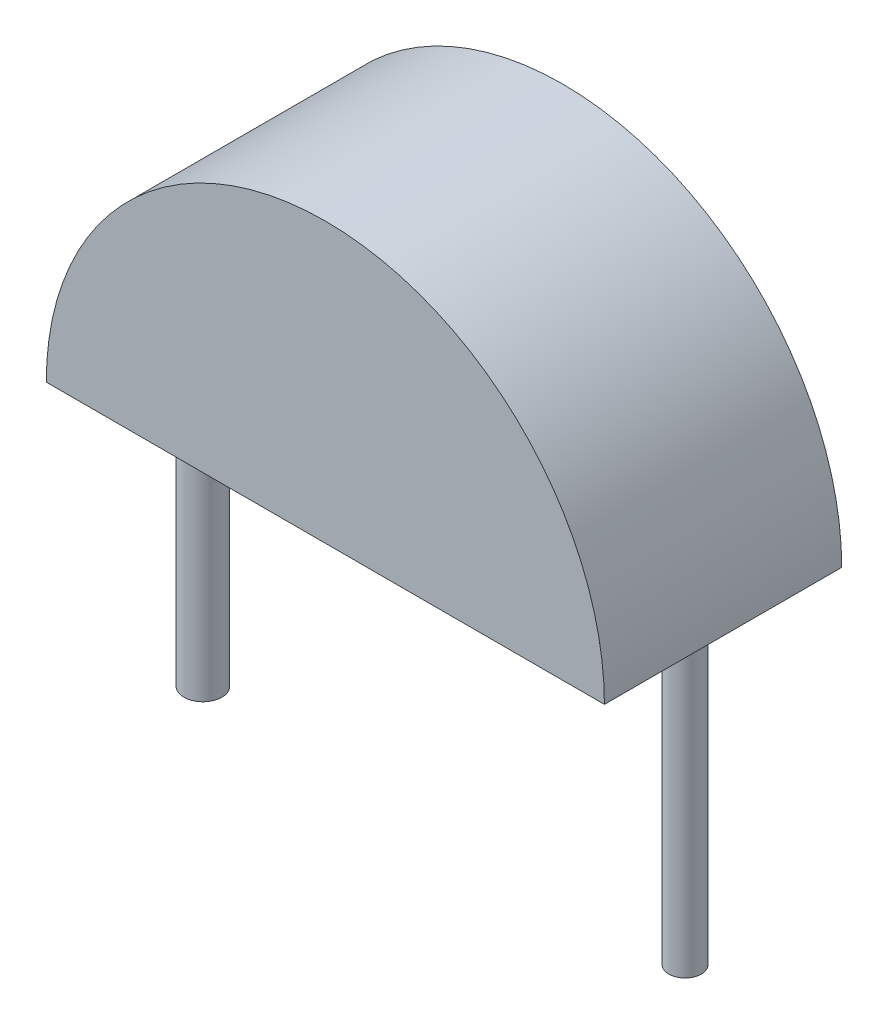
from build123d import *

# Parameters (mm, degrees)
BOSS_EXTRUDE1_DEPTH = 2.5
SKETCH2_R           = 0.2
SKETCH2_R_2         = 0.171619636
BOSS_EXTRUDE2_DEPTH = 3.2


with BuildPart() as part:
    # Sketch1 → Boss-Extrude1 (new body)
    with BuildSketch(Plane.XY):
        with BuildLine():
            Line((-2.94, 0), (2.94, 0))
            ThreePointArc((2.94, 0), (0, 2.94), (-2.94, 0))
        make_face()
    extrude(amount=BOSS_EXTRUDE1_DEPTH)

    # Sketch2 → Boss-Extrude2 (add)
    with BuildSketch(Plane.XZ):
        with Locations((-2.54, 1.25)):
            Circle(SKETCH2_R)
        with Locations((2.54, 1.25)):
            Circle(SKETCH2_R_2)
    extrude(amount=BOSS_EXTRUDE2_DEPTH)


solid = part.part
